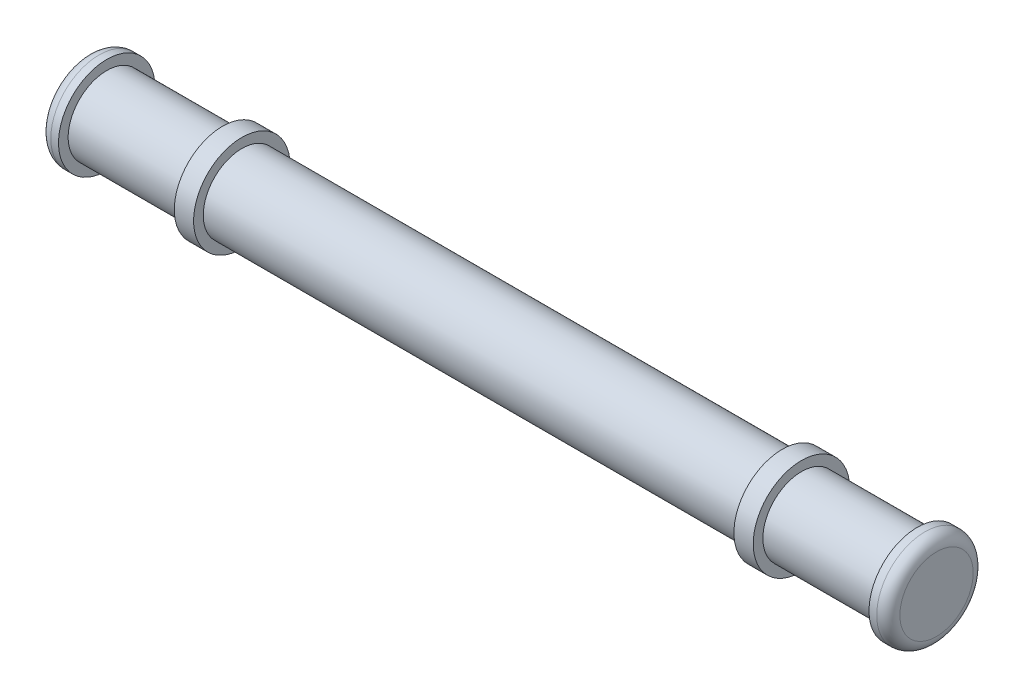
from build123d import *

# Parameters (mm, degrees)
SKETCH1_R           = 25.4
BOSS_EXTRUDE1_DEPTH = 355.6
SKETCH2_R           = 31.75
BOSS_EXTRUDE2_DEPTH = 12.7
SKETCH3_R           = 25.4
BOSS_EXTRUDE3_DEPTH = 76.2
SKETCH4_R           = 31.75
BOSS_EXTRUDE4_DEPTH = 12.7
FILLET1_R           = 7.62
FILLET2_R           = 7.62


with BuildPart() as part:
    # Sketch1 → Boss-Extrude1 (new body)
    with BuildSketch(Plane(origin=(0, 0, 0), x_dir=(0, 0, -1), z_dir=(1, 0, 0))):
        Circle(SKETCH1_R)
    extrude(amount=BOSS_EXTRUDE1_DEPTH)

    # Sketch2 → Boss-Extrude2 (add)
    with BuildSketch(Plane(origin=(355.6, 0, 0), x_dir=(0, 0, -1), z_dir=(1, 0, 0))):
        Circle(SKETCH2_R)
    boss_extrude2 = extrude(amount=BOSS_EXTRUDE2_DEPTH)

    # Sketch3 → Boss-Extrude3 (add)
    with BuildSketch(Plane(origin=(368.3, 0, 0), x_dir=(0, 0, -1), z_dir=(1, 0, 0))):
        Circle(SKETCH3_R)
    boss_extrude3 = extrude(amount=BOSS_EXTRUDE3_DEPTH)

    # Sketch4 → Boss-Extrude4 (add)
    with BuildSketch(Plane(origin=(444.5, 0, 0), x_dir=(0, 0, -1), z_dir=(1, 0, 0))):
        Circle(SKETCH4_R)
    boss_extrude4 = extrude(amount=BOSS_EXTRUDE4_DEPTH)

    # Mirror1: Boss-Extrude2, Boss-Extrude3, Boss-Extrude4 across plane
    add(boss_extrude2.mirror(Plane.ZY.offset(-177.8)))
    add(boss_extrude3.mirror(Plane.ZY.offset(-177.8)))
    add(boss_extrude4.mirror(Plane.ZY.offset(-177.8)))

    # Fillet1
    fillet1_edges = [part.edges().sort_by_distance(p)[0] for p in [
        (457.2, 0, 31.75),
    ]]
    fillet(fillet1_edges, radius=FILLET1_R)

    # Fillet2
    fillet2_edges = [part.edges().sort_by_distance(p)[0] for p in [
        (-101.6, 0, 31.75),
    ]]
    fillet(fillet2_edges, radius=FILLET2_R)


solid = part.part
